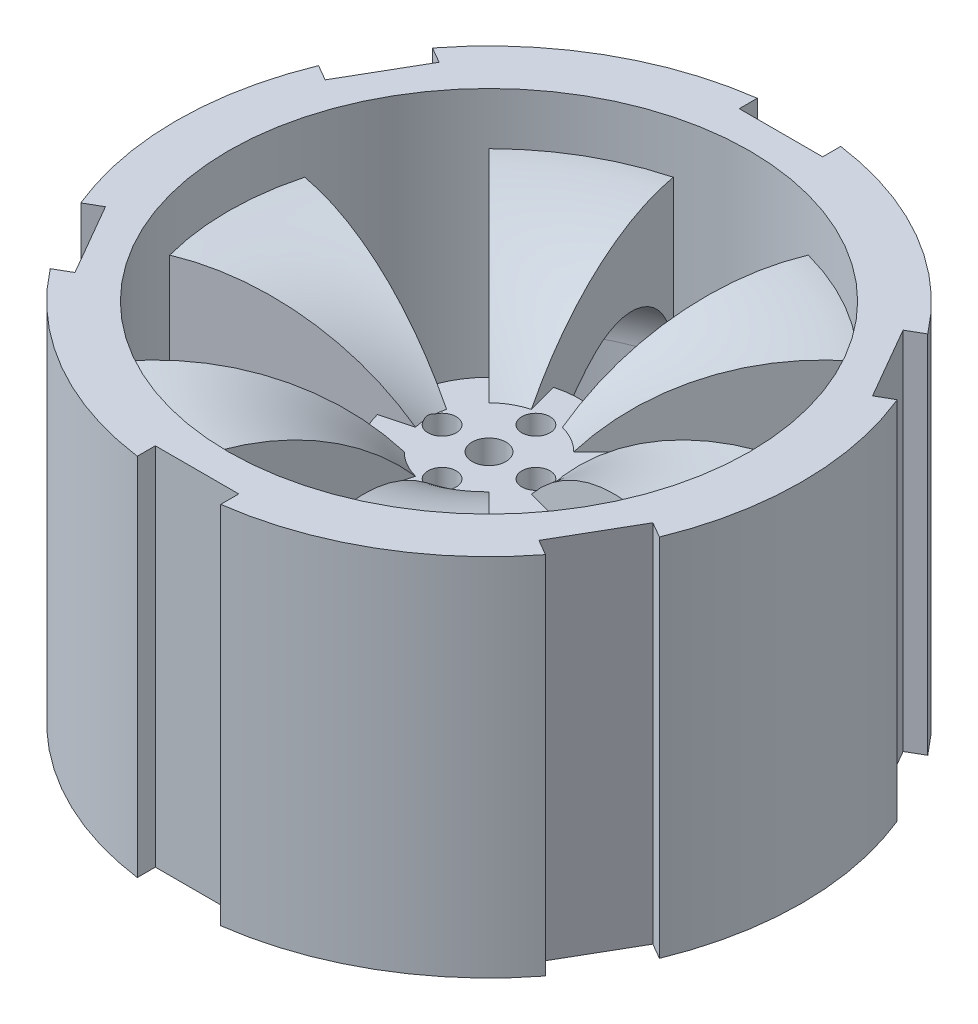
from build123d import *

# Parameters (mm, degrees)
SKETCH1_R           = 17.5
BOSS_EXTRUDE1_DEPTH = 10
SKETCH3_R           = 60
SKETCH3_R_2         = 50
BOSS_EXTRUDE2_DEPTH = 35
REVOLVE1_ANGLE      = 30
CIRPATTERN1_COUNT   = 6
SKETCH5_R           = 3.25
SKETCH5_R_2         = 2.7
CUT_EXTRUDE1_DEPTH  = 35
FILLET1_R           = 15
SKETCH6_W           = 16
SKETCH6_H           = 8
CUT_EXTRUDE2_DEPTH  = 79
CIRPATTERN2_COUNT   = 6


with BuildPart() as part:
    # Sketch1 → Boss-Extrude1 (new, symmetric)
    with BuildSketch(Plane(origin=(0, 0, 0), x_dir=(1, 0, 0), z_dir=(0, 1, 0))):
        with Locations(Location((0, 0, 0), (0, 0, 270))):
            Circle(SKETCH1_R)
    extrude(amount=BOSS_EXTRUDE1_DEPTH, both=True)



with BuildPart() as body_2:
    # Sketch3 → Boss-Extrude2 (new, symmetric)
    with BuildSketch(Plane(origin=(0, 0, 0), x_dir=(1, 0, 0), z_dir=(0, 1, 0))):
        with Locations(Location((0, 0, 0), (0, 0, 270))):
            Circle(SKETCH3_R)
        with Locations(Location((0, 0, 0), (0, 0, 270))):
            Circle(SKETCH3_R_2, mode=Mode.SUBTRACT)
    extrude(amount=BOSS_EXTRUDE2_DEPTH, both=True)


with BuildPart() as part_1:
    add(part.part)

    add(body_2.part)  # Revolve1 merges body 2
    # Sketch4 → Revolve1 (revolve, symmetric)
    with BuildSketch(Plane.XY) as revolve1_sk:
        with BuildLine():
            Line((-11.5, 10), (-17.5, 10))
            Line((-17.5, 10), (-17.5, 0))
            ThreePointArc((-17.5, 0), (-32.196388549, 10.049237216), (-50, 10))
            Line((-50, 10), (-50, 25))
            ThreePointArc((-50, 25), (-28.926622004, 22.180003523), (-11.5, 10))
        make_face()
    revolve1 = revolve(axis=Axis((0, 10, 0), (0, -1, 0)), revolution_arc=REVOLVE1_ANGLE / 2)
    revolve1 = revolve1 + revolve(revolve1_sk.sketch, axis=Axis((0, 10, 0), (0, 1, 0)), revolution_arc=REVOLVE1_ANGLE / 2)

    # CirPattern1: Revolve1 ×6 about axis
    cirpattern1_axis = Axis((0, 0, 0), (0, 1, 0))
    for i in range(1, CIRPATTERN1_COUNT):
        add(revolve1.rotate(cirpattern1_axis, i * 360 / CIRPATTERN1_COUNT))

    # Sketch5 → Cut-Extrude1 (cut, symmetric)
    with BuildSketch(Plane(origin=(0, 10, 0), x_dir=(1, 0, 0), z_dir=(0, 1, 0))):
        with Locations(Location((0, 0, 0), (0, 0, 270))):
            Circle(SKETCH5_R)
        with Locations(Location((0, 9, 0), (0, 0, 270))):
            Circle(SKETCH5_R_2)
        with Locations(Location((9, 0, 0), (0, 0, 270))):
            Circle(SKETCH5_R_2)
        with Locations(Location((0, -9, 0), (0, 0, 270))):
            Circle(SKETCH5_R_2)
        with Locations(Location((-9, 0, 0), (0, 0, 270))):
            Circle(SKETCH5_R_2)
    extrude(amount=CUT_EXTRUDE1_DEPTH, both=True, mode=Mode.SUBTRACT)

    # Fillet1
    fillet1_edges = [part_1.edges().sort_by_distance(p)[0] for p in [
        (-50, 10, 0),
        (-25, 10, 43.301270189),
        (25, 10, 43.301270189),
        (50, 10, 0),
        (25, 10, -43.301270189),
        (-25, 10, -43.301270189),
    ]]
    fillet(fillet1_edges, radius=FILLET1_R)

    # Sketch6 → Cut-Extrude2 (cut)
    with BuildSketch(Plane(origin=(0, 35, 0), x_dir=(1, 0, 0), z_dir=(0, 1, 0))):
        with Locations((0, 60)):
            Rectangle(SKETCH6_W, SKETCH6_H)
    cut_extrude2 = extrude(amount=-CUT_EXTRUDE2_DEPTH, mode=Mode.SUBTRACT)

    # CirPattern2: Cut-Extrude2 ×6 about axis
    cirpattern2_axis = Axis((0, 0, 0), (0, 1, 0))
    for i in range(1, CIRPATTERN2_COUNT):
        add(cut_extrude2.rotate(cirpattern2_axis, i * 360 / CIRPATTERN2_COUNT), mode=Mode.SUBTRACT)


solid = part_1.part
